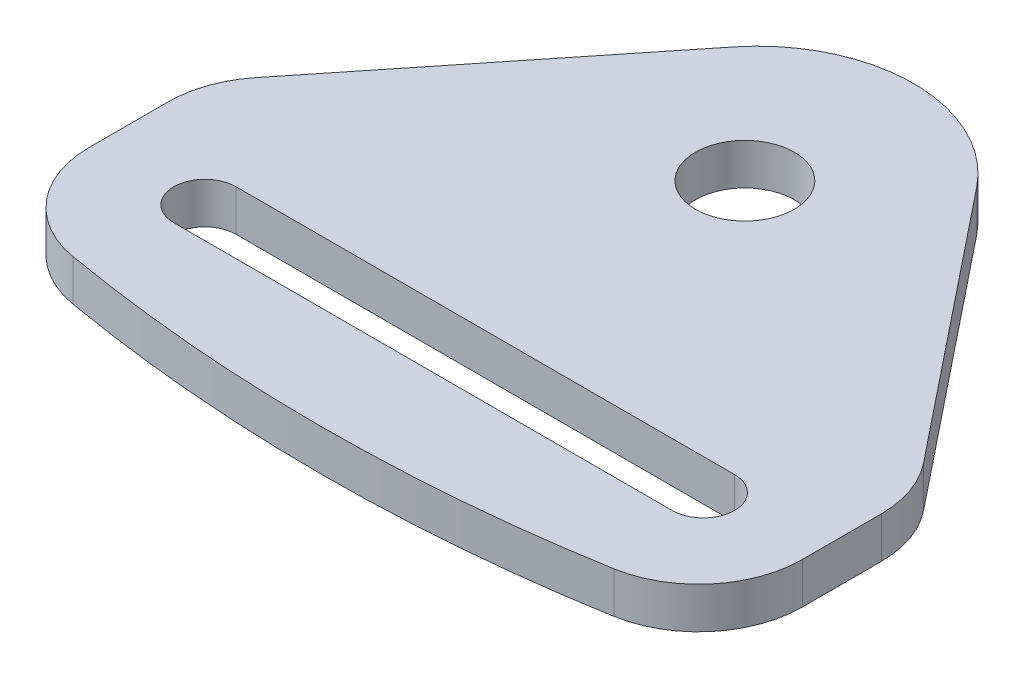
from build123d import *

# Parameters (mm, degrees)
SKETCH1_R           = 4.7625
BOSS_EXTRUDE1_DEPTH = 3.96875
FILLET1_R           = 10
FILLET2_R           = 15


with BuildPart() as part:
    # Sketch1 → Boss-Extrude1 (new body)
    with BuildSketch(Plane(origin=(0, 0, 0), x_dir=(1, 0, 0), z_dir=(0, 1, 0))):
        with BuildLine():
            Line((-68.7, 0), (-68.7, 19.3))
            Line((-68.7, 19.3), (-34.35, 62.254365319))
            Line((-34.35, 62.254365319), (0, 19.3))
            Line((0, 19.3), (0, 0))
            ThreePointArc((0, 0), (-34.35, -3.905912777), (-68.7, 0))
        make_face()
        with Locations((-34.35, 37)):
            Circle(SKETCH1_R, mode=Mode.SUBTRACT)
        with BuildLine():
            Line((-58.35, 12), (-10.35, 12))
            ThreePointArc((-10.35, 12), (-7.35, 9), (-10.35, 6))
            Line((-10.35, 6), (-58.35, 6))
            ThreePointArc((-58.35, 6), (-61.35, 9), (-58.35, 12))
        make_face(mode=Mode.SUBTRACT)
    extrude(amount=BOSS_EXTRUDE1_DEPTH)

    # Fillet1
    fillet1_edges = [part.edges().sort_by_distance(p)[0] for p in [
        (-68.7, 1.984375, 0),
        (-68.7, 1.984375, -19.3),
        (0, 1.984375, -19.3),
        (0, 1.984375, 0),
    ]]
    fillet(fillet1_edges, radius=FILLET1_R)

    # Fillet2
    fillet2_edges = [part.edges().sort_by_distance(p)[0] for p in [
        (-34.35, 1.984375, -62.254365319),
    ]]
    fillet(fillet2_edges, radius=FILLET2_R)


solid = part.part
